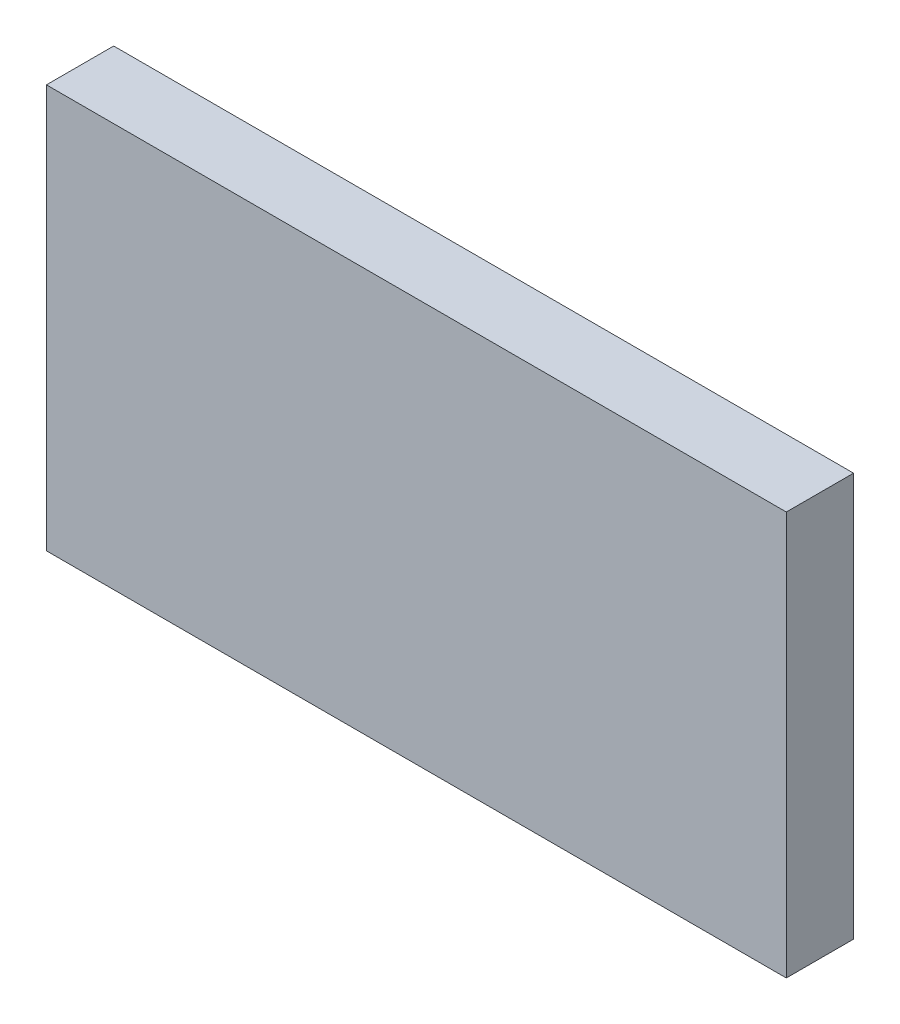
from build123d import *

# Parameters (mm, degrees)
SKETCH2_W           = 33
SKETCH2_H           = 18
BOSS_EXTRUDE1_DEPTH = 3


with BuildPart() as part:
    # Sketch2 → Boss-Extrude1 (new body)
    with BuildSketch(Plane.XY):
        with Locations((16.5, 9)):
            Rectangle(SKETCH2_W, SKETCH2_H)
    extrude(amount=BOSS_EXTRUDE1_DEPTH)


solid = part.part
